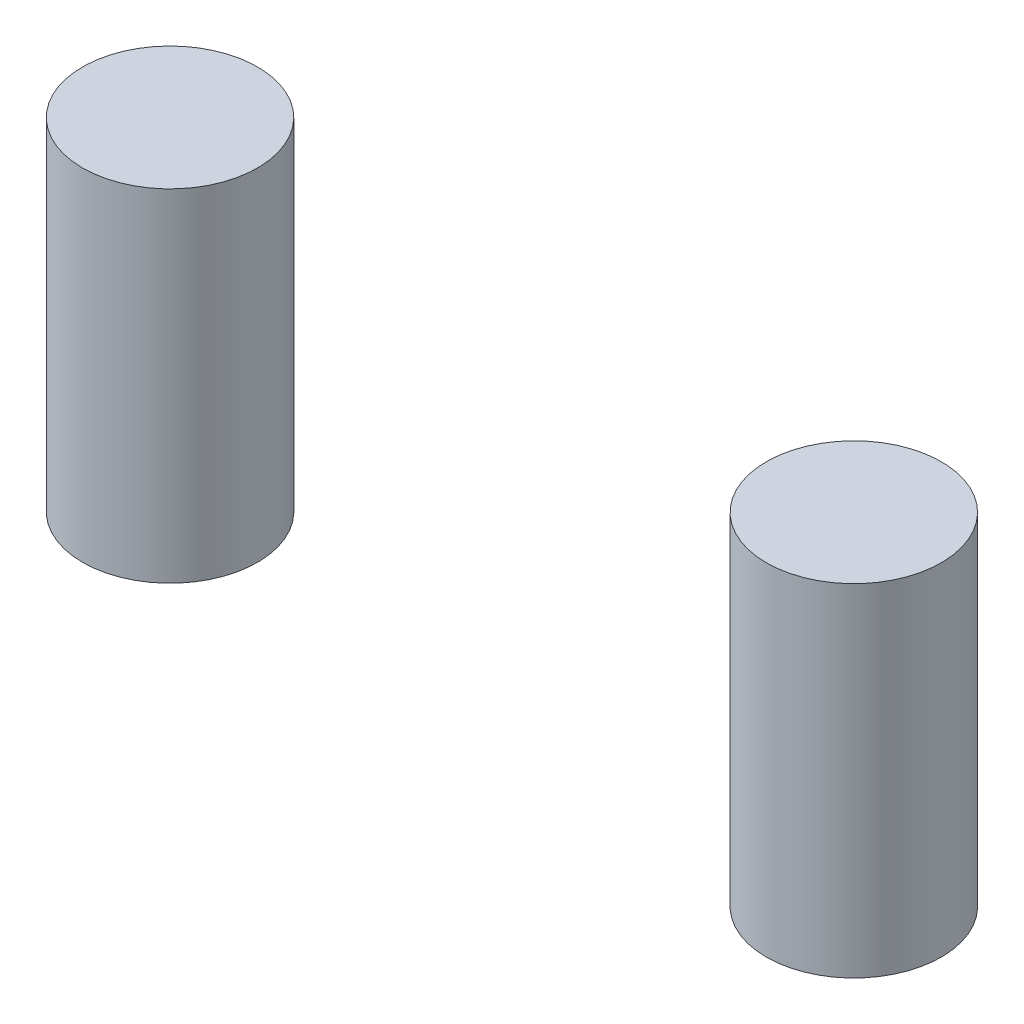
from build123d import *

# Parameters (mm, degrees)
SKETCH1_R             = 3.075
BOSS_EXTRUDE1_DEPTH   = 12
BOSS_EXTRUDE1_2_DEPTH = 12


with BuildPart() as part:
    # Sketch1 → Boss-Extrude1 (new body)
    with BuildSketch(Plane(origin=(0, 0, 0), x_dir=(1, 0, 0), z_dir=(0, 1, 0))):
        with Locations((3.099999428, -3.099999905)):
            Circle(SKETCH1_R)
    extrude(amount=BOSS_EXTRUDE1_DEPTH)


with BuildPart() as body_2:
    # Sketch1 → Boss-Extrude1 2 (new body)
    with BuildSketch(Plane(origin=(0, 0, 0), x_dir=(1, 0, 0), z_dir=(0, 1, 0))):
        with Locations((27.125, -3.099999905)):
            Circle(SKETCH1_R)
    extrude(amount=BOSS_EXTRUDE1_2_DEPTH)


solid = Compound([part.part, body_2.part])
